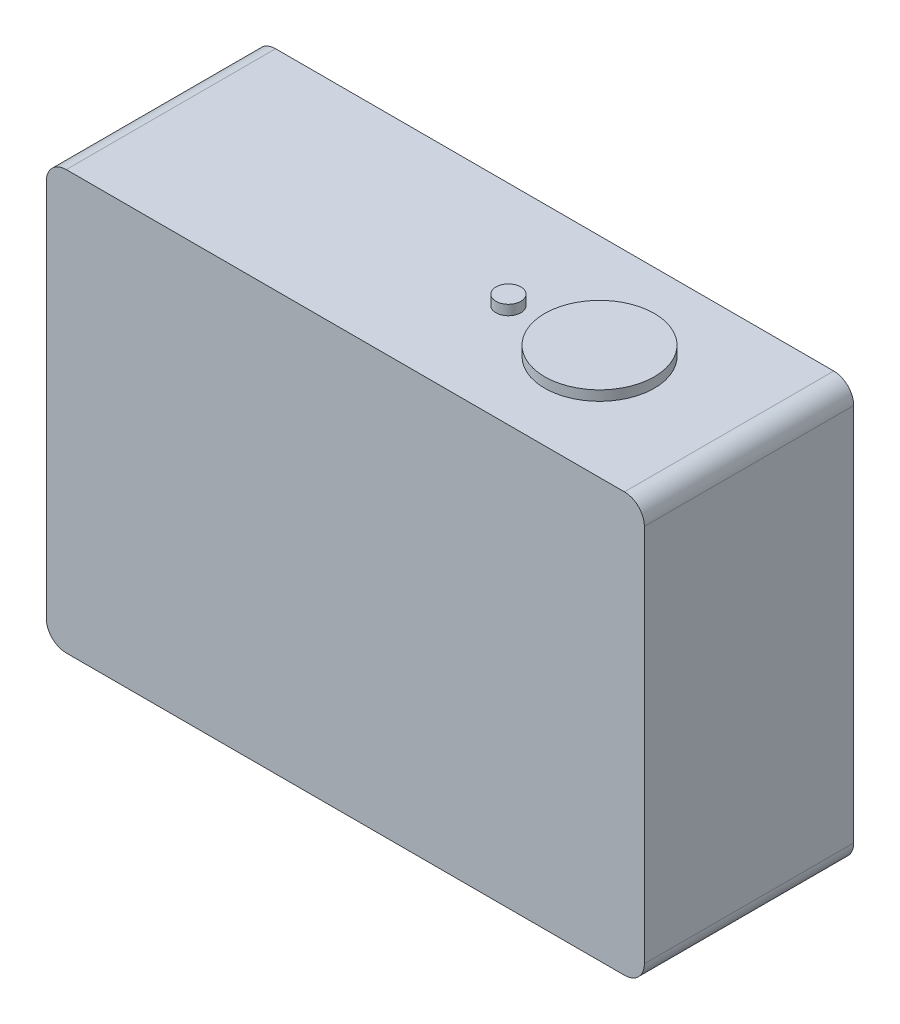
from build123d import *

# Parameters (mm, degrees)
SKETCH1_W           = 60
SKETCH1_H           = 42
BOSS_EXTRUDE1_DEPTH = 21
FILLET1_R           = 2
SKETCH2_R           = 11.875268611
SKETCH2_R_2         = 8.872907523
BOSS_EXTRUDE2_DEPTH = 7.5
SKETCH3_R           = 7.41919465
BOSS_EXTRUDE3_DEPTH = 2
SKETCH4_R           = 5.5
BOSS_EXTRUDE5_DEPTH = 1
SKETCH5_R           = 1.25
BOSS_EXTRUDE6_DEPTH = 1
SKETCH7_R           = 8.872907523
BOSS_EXTRUDE8_DEPTH = 4


with BuildPart() as part:
    # Sketch1 → Boss-Extrude1 (new body)
    with BuildSketch(Plane.XY):
        Rectangle(SKETCH1_W, SKETCH1_H)
    extrude(amount=BOSS_EXTRUDE1_DEPTH)

    # Fillet1
    fillet1_edges = [part.edges().sort_by_distance(p)[0] for p in [
        (30, -21, 10.5),
        (-30, -21, 10.5),
        (-30, 21, 10.5),
        (30, 21, 10.5),
    ]]
    fillet(fillet1_edges, radius=FILLET1_R)

    # Sketch2 → Boss-Extrude2 (add)
    with BuildSketch(Plane(origin=(0, 0, 0), x_dir=(-1, 0, 0), z_dir=(0, 0, -1))):
        with Locations((13, 0)):
            Circle(SKETCH2_R)
        with Locations((13, 0)):
            Circle(SKETCH2_R_2, mode=Mode.SUBTRACT)
    extrude(amount=BOSS_EXTRUDE2_DEPTH)

    # Sketch3 → Boss-Extrude3 (add)
    with BuildSketch(Plane.XY):
        with Locations((15, 0)):
            Circle(SKETCH3_R)
    extrude(amount=-BOSS_EXTRUDE3_DEPTH)

    # Sketch4 → Boss-Extrude5 (add)
    with BuildSketch(Plane(origin=(0, 21, 0), x_dir=(1, 0, 0), z_dir=(0, 1, 0))):
        with Locations(Location((15, -10.5, 0), (0, 0, 90))):  # turned: the seam where the file's is
            Circle(SKETCH4_R)
    extrude(amount=BOSS_EXTRUDE5_DEPTH)

    # Sketch5 → Boss-Extrude6 (add)
    with BuildSketch(Plane(origin=(0, 21, 0), x_dir=(1, 0, 0), z_dir=(0, 1, 0))):
        with Locations(Location((6, -10.639891408, 0), (0, 0, 90))):  # turned: the seam where the file's is
            Circle(SKETCH5_R)
    extrude(amount=BOSS_EXTRUDE6_DEPTH)

    # Sketch7 → Boss-Extrude8 (add)
    with BuildSketch(Plane(origin=(0, 0, 0), x_dir=(-1, 0, 0), z_dir=(0, 0, -1))):
        with Locations((13, 0)):
            Circle(SKETCH7_R)
    extrude(amount=BOSS_EXTRUDE8_DEPTH)


solid = part.part
